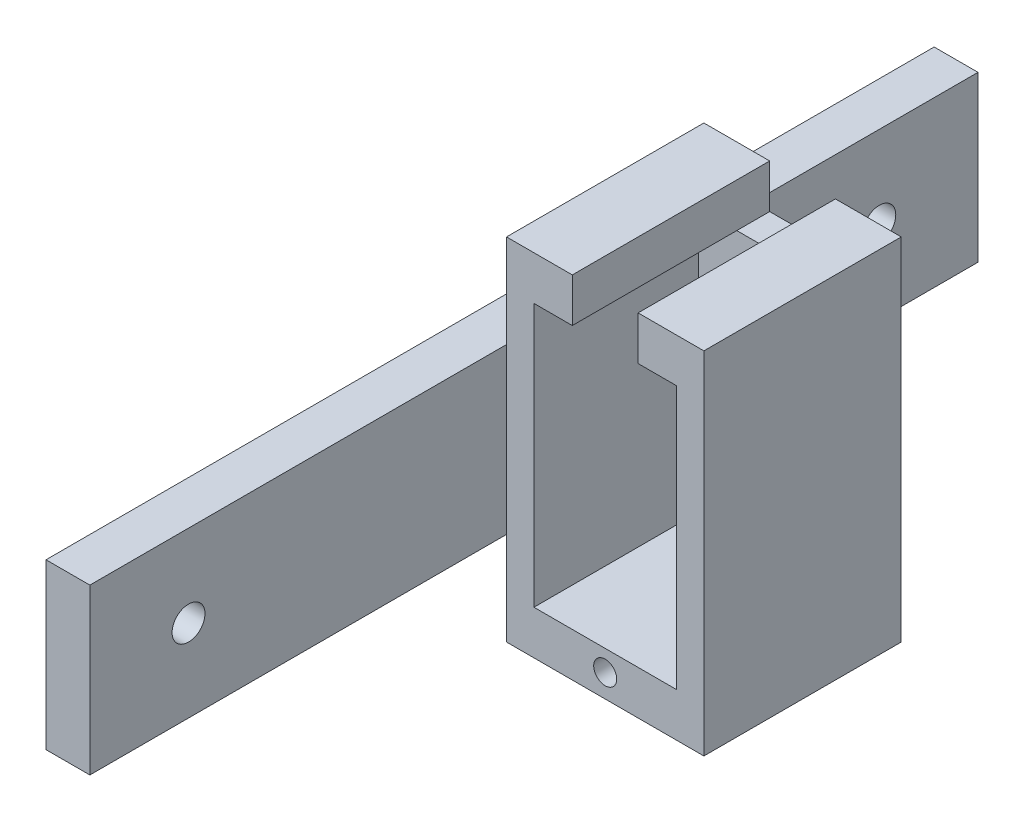
from build123d import *

# Parameters (mm, degrees)
BOSS_EXTRU_1_DEPTH      = 3
BOSS_EXTRU_2_DEPTH      = 15
ESQUISSE3_R             = 1.05
ENL_V_MAT_EXTRU_1_DEPTH = 6
ESQUISSE4_W             = 81
ESQUISSE4_H             = 15
BOSS_EXTRU_3_DEPTH      = 4
ESQUISSE5_R             = 1.5
ENL_V_MAT_EXTRU_2_DEPTH = 4


with BuildPart() as part:
    # Esquisse1 → Boss.-Extru.1 (new body)
    with BuildSketch(Plane.XY):
        Polygon((-12, 32), (-12, 28), (-6, 28), (-6, 32), (0, 32), (0, 0), (-18, 0), (-18, 32), align=None)
    extrude(amount=BOSS_EXTRU_1_DEPTH)

    # Esquisse2 → Boss.-Extru.2 (add)
    with BuildSketch(Plane.XY.offset(3)):
        Polygon((-18, 0), (0, 0), (0, 32), (-6, 32), (-6, 28), (-2.5, 28), (-2.5, 4), (-15.5, 4), (-15.5, 28), (-12, 28), (-12, 32), (-18, 32), align=None)
    extrude(amount=BOSS_EXTRU_2_DEPTH)

    # Esquisse3 → Enlèv. mat.-Extru.1 (cut)
    with BuildSketch(Plane.XY.offset(18)):
        with Locations((-9, 2.1)):
            Circle(ESQUISSE3_R)
    extrude(amount=-ENL_V_MAT_EXTRU_1_DEPTH, mode=Mode.SUBTRACT)

    # Esquisse4 → Boss.-Extru.3 (add)
    with BuildSketch(Plane.ZY.offset(18)):
        with Locations((15.5, 16)):
            Rectangle(ESQUISSE4_W, ESQUISSE4_H)
    extrude(amount=BOSS_EXTRU_3_DEPTH)

    # Esquisse5 → Enlèv. mat.-Extru.2 (cut)
    with BuildSketch(Plane.ZY.offset(22)):
        with Locations((-16, 16)):
            Circle(ESQUISSE5_R)
        with Locations((47, 16)):
            Circle(ESQUISSE5_R)
    extrude(amount=-ENL_V_MAT_EXTRU_2_DEPTH, mode=Mode.SUBTRACT)


solid = part.part
